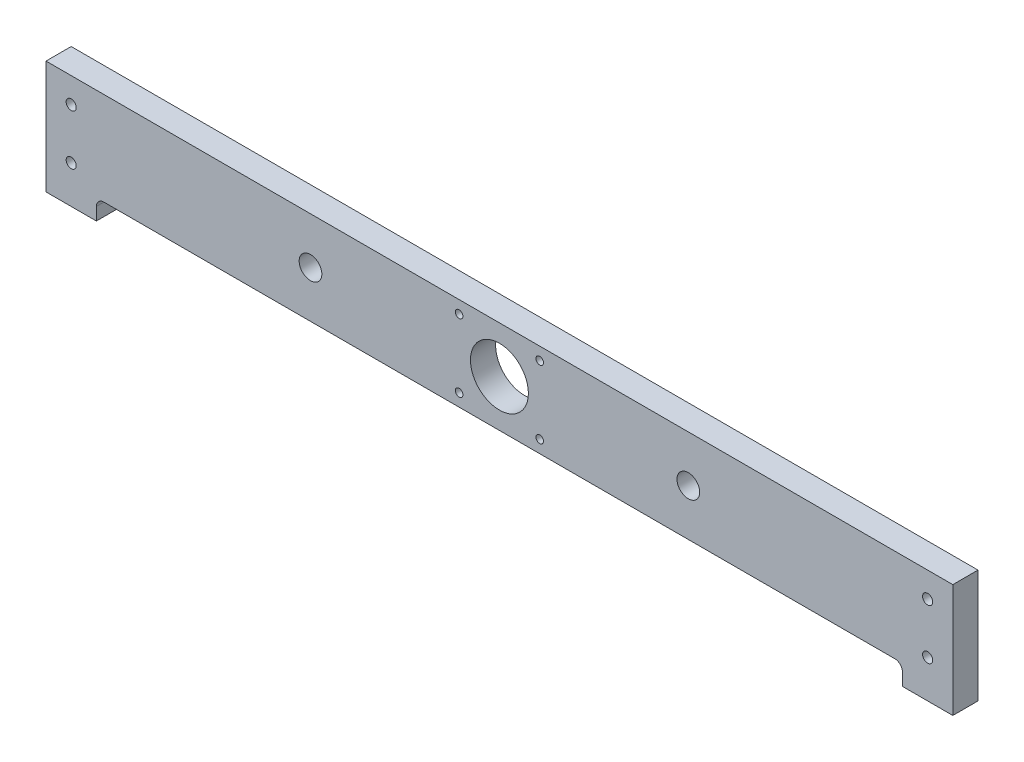
from build123d import *

# Parameters (mm, degrees)
SKETCH1_R           = 2
SKETCH1_R_2         = 11.5
SKETCH1_R_3         = 4.5
SKETCH1_R_4         = 1.5
BOSS_EXTRUDE1_DEPTH = 10


with BuildPart() as part:
    # Sketch1 → Boss-Extrude1 (new body)
    with BuildSketch(Plane.XY):
        with BuildLine():
            Line((0, 0), (360, 0))
            Line((360, 0), (360, -45))
            Line((360, -45), (340, -45))
            Line((340, -45), (340, -40))
            ThreePointArc((340, -40), (339.121320344, -37.878679656), (337, -37))
            Line((337, -37), (23, -37))
            ThreePointArc((23, -37), (20.878679656, -37.878679656), (20, -40))
            Line((20, -40), (20, -45))
            Line((20, -45), (0, -45))
            Line((0, -45), (0, 0))
        make_face()
        with Locations((350, -10)):
            Circle(SKETCH1_R, mode=Mode.SUBTRACT)
        with Locations((350, -30)):
            Circle(SKETCH1_R, mode=Mode.SUBTRACT)
        with Locations((10, -10)):
            Circle(SKETCH1_R, mode=Mode.SUBTRACT)
        with Locations((10, -30.004476127)):
            Circle(SKETCH1_R, mode=Mode.SUBTRACT)
        with Locations((180, -18.5)):
            Circle(SKETCH1_R_2, mode=Mode.SUBTRACT)
        with Locations((255, -18.5)):
            Circle(SKETCH1_R_3, mode=Mode.SUBTRACT)
        with Locations((105, -18.5)):
            Circle(SKETCH1_R_3, mode=Mode.SUBTRACT)
        with Locations((164, -5)):
            Circle(SKETCH1_R_4, mode=Mode.SUBTRACT)
        with Locations((196, -5)):
            Circle(SKETCH1_R_4, mode=Mode.SUBTRACT)
        with Locations((196, -32)):
            Circle(SKETCH1_R_4, mode=Mode.SUBTRACT)
        with Locations((164, -32)):
            Circle(SKETCH1_R_4, mode=Mode.SUBTRACT)
    extrude(amount=BOSS_EXTRUDE1_DEPTH)


solid = part.part
